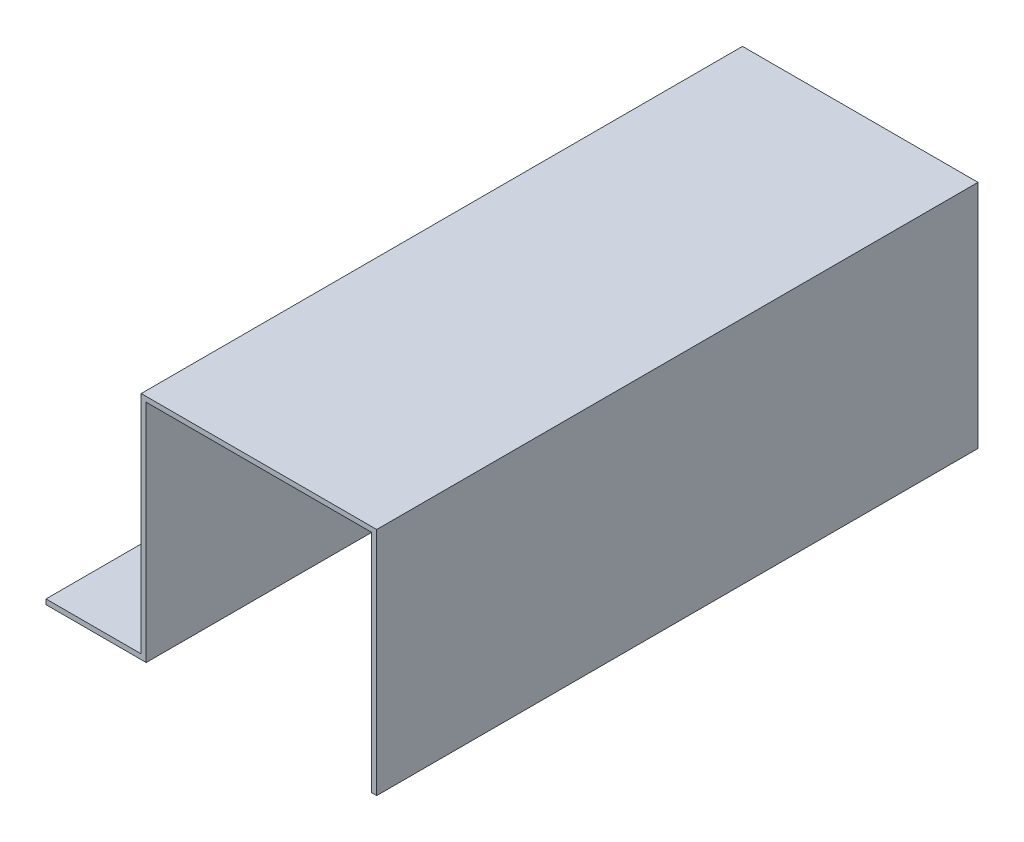
from build123d import *

# Parameters (mm, degrees)
BOSS_EXTRUDE1_DEPTH = 120
SKETCH2_R           = 2.65
CUT_EXTRUDE1_DEPTH  = 200


with BuildPart() as part:
    # Sketch1 → Boss-Extrude1 (new body)
    with BuildSketch(Plane.XY):
        Polygon((0, 0), (20, 0), (20, 45), (65, 45), (65, 0), (66, 0), (66, 46), (19, 46), (19, 1), (0, 1), align=None)
    extrude(amount=BOSS_EXTRUDE1_DEPTH)

    # Sketch2 → Cut-Extrude1 (cut)
    with BuildSketch(Plane(origin=(0, 1, 0), x_dir=(1, 0, 0), z_dir=(0, 1, 0))):
        with Locations((9.5, -30)):
            Circle(SKETCH2_R)
        with Locations((9.5, -90)):
            Circle(SKETCH2_R)
    extrude(amount=-CUT_EXTRUDE1_DEPTH, mode=Mode.SUBTRACT)


solid = part.part
